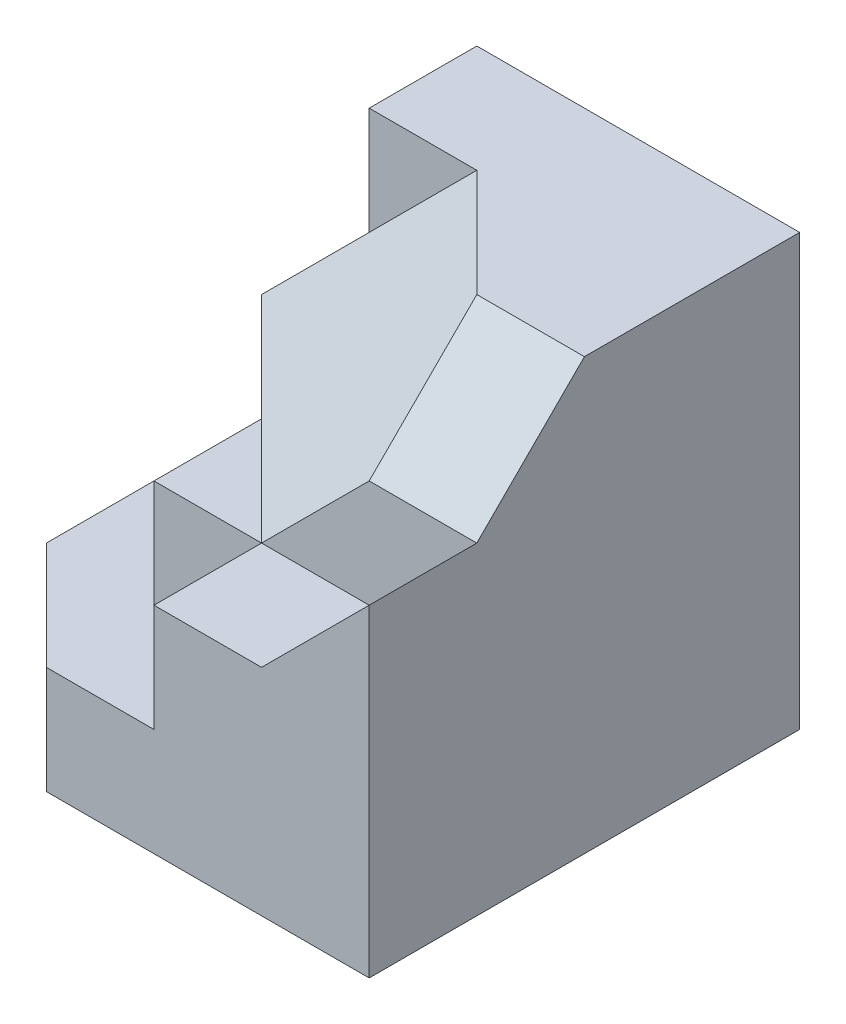
from build123d import *

# Parameters (mm, degrees)
BOSS_EXTRUDE1_DEPTH = 20
SKETCH2_W           = 5
SKETCH2_H           = 20
BOSS_EXTRUDE2_DEPTH = 5
CUT_EXTRUDE1_DEPTH  = 5
SKETCH4_W           = 5
SKETCH4_H           = 15
BOSS_EXTRUDE4_DEPTH = 5
CUT_EXTRUDE3_DEPTH  = 5
SKETCH7_W           = 5
SKETCH7_H           = 15
BOSS_EXTRUDE5_DEPTH = 5
CUT_EXTRUDE4_DEPTH  = 5
BOSS_EXTRUDE6_DEPTH = 20
CUT_EXTRUDE15_DEPTH = 61
BOSS_EXTRUDE7_DEPTH = 5
SKETCH11_W          = 5
SKETCH11_H          = 5
BOSS_EXTRUDE8_DEPTH = 5


with BuildPart() as part:
    # Sketch1 → Boss-Extrude1 (new body)
    with BuildSketch(Plane(origin=(0, 0, 0), x_dir=(1, 0, 0), z_dir=(0, 1, 0))):
        Polygon((-23.791469194, 10), (-8.791469194, 10), (-8.791469194, 0), (-13.791469194, 0), (-18.791469194, 5), (-23.791469194, 5), align=None)
    extrude(amount=BOSS_EXTRUDE1_DEPTH)

    # Sketch2 → Boss-Extrude2 (add)
    with BuildSketch(Plane.XY):
        with Locations((-11.291469194, 10)):
            Rectangle(SKETCH2_W, SKETCH2_H)
    extrude(amount=BOSS_EXTRUDE2_DEPTH)

    # Sketch3 → Cut-Extrude1 (cut)
    with BuildSketch(Plane.ZY.offset(13.791469194)):
        Polygon((0, 20), (5, 15), (5, 20), align=None)
    extrude(amount=-CUT_EXTRUDE1_DEPTH, mode=Mode.SUBTRACT)

    # Sketch4 → Boss-Extrude4 (add)
    with BuildSketch(Plane.ZY.offset(23.791469194)):
        with Locations((-7.5, 7.5)):
            Rectangle(SKETCH4_W, SKETCH4_H)
    extrude(amount=BOSS_EXTRUDE4_DEPTH)

    # Sketch6 → Cut-Extrude3 (cut)
    with BuildSketch(Plane.XY.offset(-5)):
        Polygon((-23.791469194, 15), (-28.791469194, 15), (-28.791469194, 10), align=None)
    extrude(amount=-CUT_EXTRUDE3_DEPTH, mode=Mode.SUBTRACT)

    # Sketch7 → Boss-Extrude5 (add)
    with BuildSketch(Plane.XY.offset(5)):
        with Locations((-11.291469194, 7.5)):
            Rectangle(SKETCH7_W, SKETCH7_H)
    extrude(amount=BOSS_EXTRUDE5_DEPTH)

    # Sketch8 → Cut-Extrude4 (cut)
    with BuildSketch(Plane.XY.offset(10)):
        Polygon((-8.791469194, 15), (-13.791469194, 15), (-13.791469194, 10), align=None)
    extrude(amount=-CUT_EXTRUDE4_DEPTH, mode=Mode.SUBTRACT)

    # Sketch9 → Boss-Extrude6 (add)
    with BuildSketch(Plane(origin=(0, 0, 0), x_dir=(-1, 0, 0), z_dir=(0, -1, 0))):
        Polygon((28.791469194, 5), (18.791469194, 5), (13.791469194, 0), (13.791469194, -5), (18.791469194, -5), align=None)
    extrude(amount=-BOSS_EXTRUDE6_DEPTH)

    # 3DSketch1 → Cut-Extrude15 (cut, along a direction that is not the sketch's normal)
    with BuildSketch(Plane(origin=(-28.791469194, 10, -5), x_dir=(0.8017837257372719, 0.2672612419124303, 0.5345224838248478), z_dir=(-0.5773502691896281, 0.5773502691896282, 0.5773502691896213))):
        Polygon((0, 0), (10.690449676, 9.258200998), (17.371980724, 6.943650748), (18.708286934, 0), (13.363062096, -4.629100499), align=None)
    extrude(amount=CUT_EXTRUDE15_DEPTH, dir=(0, 1, 0), mode=Mode.SUBTRACT)

    # Sketch10 → Boss-Extrude7 (add)
    with BuildSketch(Plane(origin=(0, 0, 0), x_dir=(-1, 0, 0), z_dir=(0, -1, 0))):
        Polygon((28.791469194, 5), (18.791469194, -5), (13.791469194, -5), (13.791469194, -10), (23.791469194, -10), (28.791469194, -5), align=None)
    extrude(amount=-BOSS_EXTRUDE7_DEPTH)

    # Sketch11 → Boss-Extrude8 (add)
    with BuildSketch(Plane(origin=(0, 5, 0), x_dir=(1, 0, 0), z_dir=(0, 1, 0))):
        with Locations((-16.291469194, -7.5)):
            Rectangle(SKETCH11_W, SKETCH11_H)
        Polygon((-23.791469194, -5), (-18.791469194, -5), (-23.791469194, 0), align=None)
    extrude(amount=BOSS_EXTRUDE8_DEPTH)


solid = part.part
